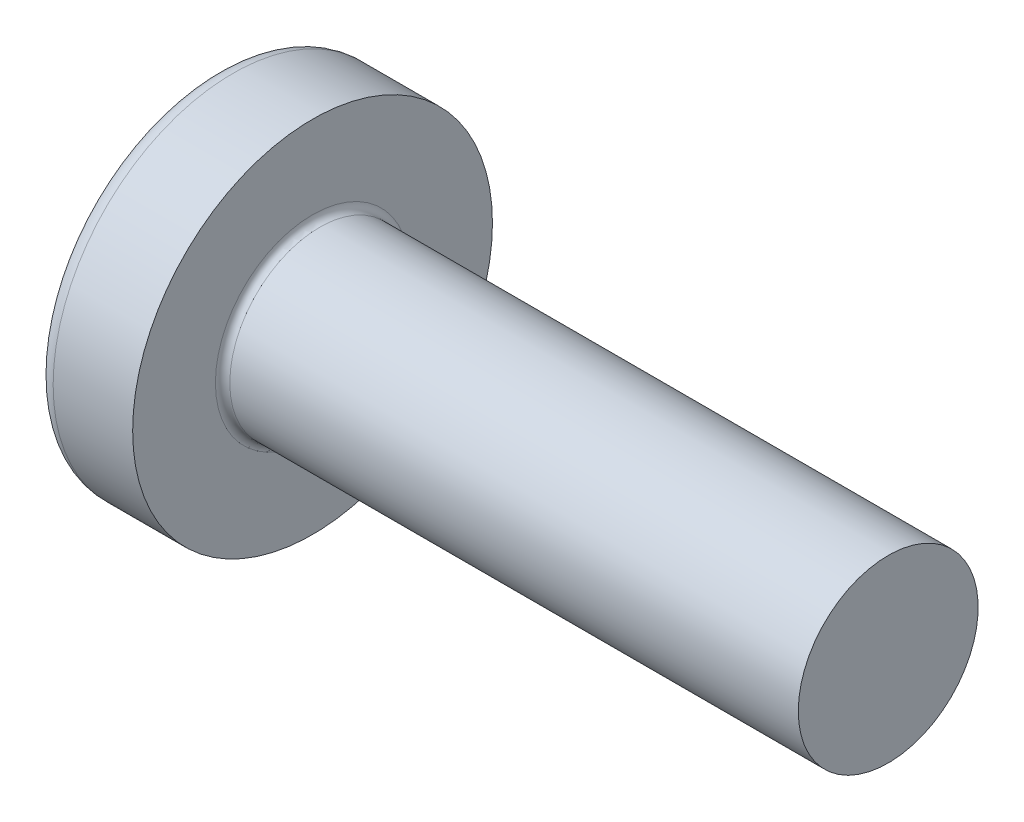
from build123d import *

# Parameters (mm, degrees)
FILLET1_R    = 0.1
SKETCH3_W    = 0.74
SKETCH3_H    = 2.6
SKETCH4_W    = 0.74
SKETCH4_H    = 1.104255426
RECPAT_COUNT = 2
RECPAT_ANGLE = 90


with BuildPart() as part:
    # BodySke → Base-Revolve (revolve)
    with BuildSketch(Plane.XY):
        with BuildLine():
            Line((2.1, 1.25), (2.1, 2.5))
            Line((2.1, 2.5), (0.99500416, 2.5))
            ThreePointArc((0.99500416, 2.5), (0.88781572, 2.474733878), (0.803195915, 2.404255319))
            ThreePointArc((0.803195915, 2.404255319), (0.206109099, 1.267435138), (0, 0))
            Line((0, 0), (10.1, 0))
            Line((10.1, 0), (10.1, 1.25))
            Line((10.1, 1.25), (2.1, 1.25))
        make_face()
    revolve(axis=Axis((-25.4, 0, 0), (1, 0, 0)))

    # Fillet1
    fillet1_edges = [part.edges().sort_by_distance(p)[0] for p in [
        (2.1, -1.25, 0),
    ]]
    fillet(fillet1_edges, radius=FILLET1_R)

    # Sketch3 → Recess section 0
    with BuildSketch(Plane(origin=(0, 0, 0), x_dir=(0, 0, -1), z_dir=(1, 0, 0))):
        Rectangle(SKETCH3_W, SKETCH3_H)
    # Sketch4 → Recess section 1
    with BuildSketch(Plane(origin=(1.5, 0, 0), x_dir=(0, 0, -1), z_dir=(1, 0, 0))):
        Rectangle(SKETCH4_W, SKETCH4_H)
    recess = loft(mode=Mode.SUBTRACT)

    # RecPat: Recess ×2 about axis
    recpat_axis = Axis((0, 0, 0), (1, 0, 0))
    for i in range(1, RECPAT_COUNT):
        add(recess.rotate(recpat_axis, i * RECPAT_ANGLE / (RECPAT_COUNT - 1)), mode=Mode.SUBTRACT)

    # RecCorSke → RecessCore (revolve, cut)
    with BuildSketch(Plane.XY):
        Polygon((0, 0), (0, 0.660890218), (1.5, 0.556), (1.680655351, 0), align=None)
    revolve(axis=Axis((-3.175, 0, 0), (1, 0, 0)), mode=Mode.SUBTRACT)


solid = part.part
